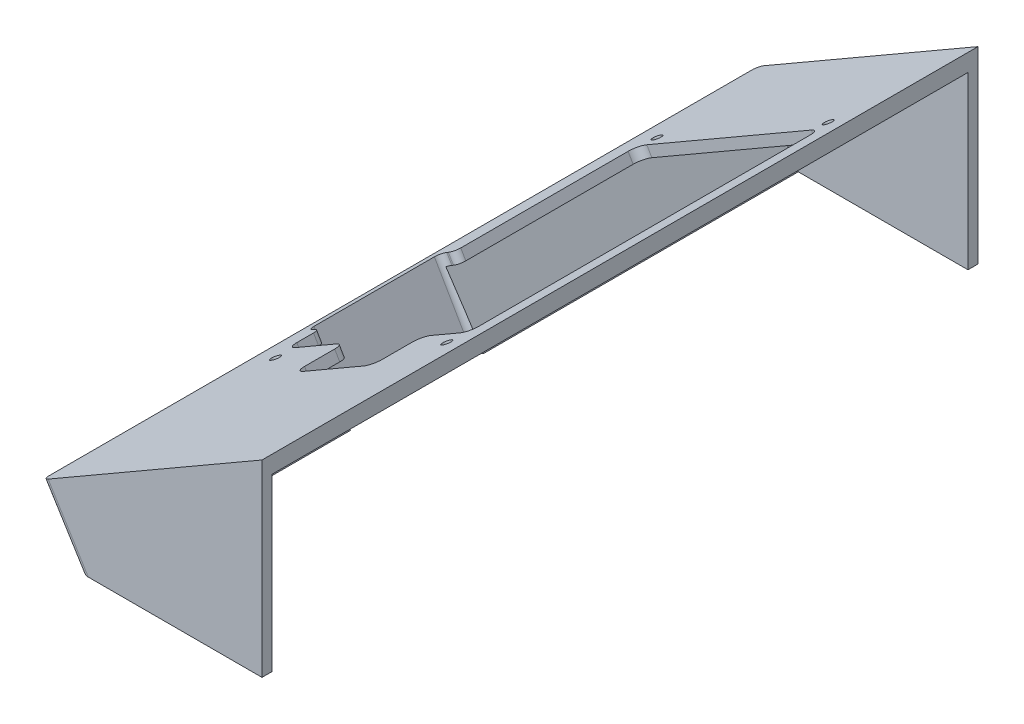
from build123d import *

# Parameters (mm, degrees)
BOSS_EXTRUDE1_DEPTH = 3
BOSS_EXTRUDE2_DEPTH = 208
BOSS_EXTRUDE4_DEPTH = 3
SKETCH3_R           = 1.375
PIHOLE_DEPTH        = 33.822362803
PIHOLE_DEPTH_BACK   = 49.737803669
CUT_EXTRUDE7_START  = -3
SKETCH11_W          = 3
SKETCH11_H          = 51.081415713
CUT_EXTRUDE7_DEPTH  = 208
FILLET1_R           = 2


with BuildPart() as part:
    # Sketch1 → Boss-Extrude1 (new body)
    with BuildSketch(Plane.XY):
        Polygon((131.589833852, 656.464158154), (185.834178461, 656.464158154), (185.834178461, 712.741726289), (120.189452854, 674.841726289), align=None)
    extrude(amount=BOSS_EXTRUDE1_DEPTH)

    # Sketch2 → Boss-Extrude2 (add)
    with BuildSketch(Plane.XY):
        Polygon((185.834178461, 712.741726289), (120.189452854, 674.841726289), (131.589833852, 656.464158154), (135.120190771, 656.464158154), (124.371071621, 673.791883395), (182.834178461, 707.545573867), (182.834178461, 656.464158154), (185.834178461, 656.464158154), align=None)
    extrude(amount=-BOSS_EXTRUDE2_DEPTH)

    # Sketch10 → Boss-Extrude4 (add)
    with BuildSketch(Plane(origin=(0, 0, -208), x_dir=(-1, 0, 0), z_dir=(0, 0, -1))):
        Polygon((-185.834178461, 712.741726289), (-120.189452854, 674.841726289), (-131.589833852, 656.464158154), (-185.834178461, 656.464158154), align=None)
    extrude(amount=BOSS_EXTRUDE4_DEPTH)

    # Sketch3 → PiHole (cut, two sides)
    with BuildSketch(Plane(origin=(-262.167676037, 454.087734998, 0), x_dir=(0.866025404, 0.5, 0), z_dir=(-0.5, 0.866025404, 0))) as pihole_sk:
        with Locations((450.507982584, 172.9)):
            Circle(SKETCH3_R)
        with Locations((509.607982584, 172.9)):
            Circle(SKETCH3_R)
        with Locations((509.607982584, 58.9)):
            Circle(SKETCH3_R)
        with Locations((450.507982584, 58.9)):
            Circle(SKETCH3_R)
        with BuildLine():
            Line((451.507982584, 169), (508.307982584, 169))
            ThreePointArc((508.307982584, 169), (510.429302927, 168.121320344), (511.307982584, 166))
            Line((511.307982584, 166), (511.307982584, 67))
            ThreePointArc((511.307982584, 67), (510.429302927, 64.878679656), (508.307982584, 64))
            Line((508.307982584, 64), (498.307982584, 64))
            ThreePointArc((498.307982584, 64), (496.18666224, 63.121320344), (495.307982584, 61))
            Line((495.307982584, 61), (495.307982584, 52))
            ThreePointArc((495.307982584, 52), (494.429302927, 49.878679656), (492.307982584, 49))
            Line((492.307982584, 49), (471.507982584, 49))
            ThreePointArc((471.507982584, 49), (469.38666224, 49.878679656), (468.507982584, 52))
            Line((468.507982584, 52), (468.507982584, 61))
            ThreePointArc((468.507982584, 61), (467.629302927, 63.121320344), (465.507982584, 64))
            Line((465.507982584, 64), (451.507982584, 64))
            ThreePointArc((451.507982584, 64), (449.38666224, 64.878679656), (448.507982584, 67))
            Line((448.507982584, 67), (448.507982584, 72))
            ThreePointArc((448.507982584, 72), (447.922196146, 73.414213562), (446.507982584, 74))
            Line((446.507982584, 74), (446.007982584, 74))
            ThreePointArc((446.007982584, 74), (444.593769021, 74.585786438), (444.007982584, 76))
            Line((444.007982584, 76), (444.007982584, 112))
            ThreePointArc((444.007982584, 112), (444.593769021, 113.414213562), (446.007982584, 114))
            Line((446.007982584, 114), (446.507982584, 114))
            ThreePointArc((446.507982584, 114), (447.922196146, 114.585786438), (448.507982584, 116))
            Line((448.507982584, 116), (448.507982584, 166))
            ThreePointArc((448.507982584, 166), (449.38666224, 168.121320344), (451.507982584, 169))
        make_face()
    extrude(amount=PIHOLE_DEPTH, mode=Mode.SUBTRACT)
    extrude(pihole_sk.sketch, amount=-PIHOLE_DEPTH_BACK, mode=Mode.SUBTRACT)

    # Sketch11 → Cut-Extrude7 (cut)
    with BuildSketch(Plane.XY.offset(3).offset(CUT_EXTRUDE7_START)):
        with Locations((184.334178461, 682.004866011)):
            Rectangle(SKETCH11_W, SKETCH11_H)
    extrude(amount=-CUT_EXTRUDE7_DEPTH, mode=Mode.SUBTRACT)

    # Fillet1
    fillet1_edges = [part.edges().sort_by_distance(p)[0] for p in [
        (125.889643353, 665.652942222, 3),
        (125.889643353, 665.652942222, -211),
    ]]
    fillet(fillet1_edges, radius=FILLET1_R)


solid = part.part
